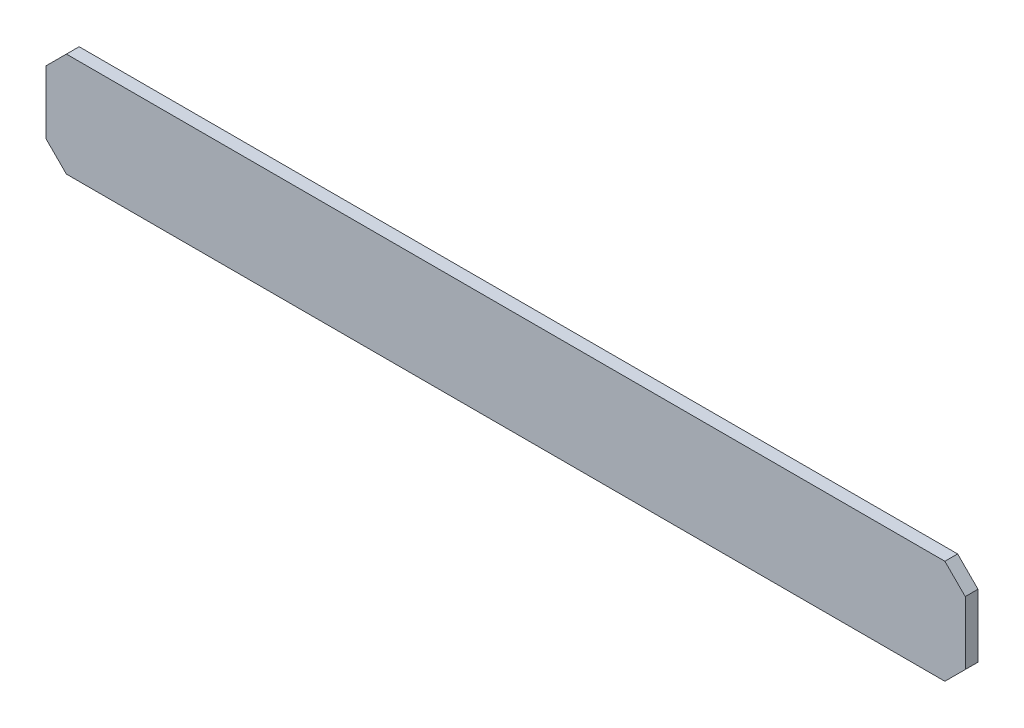
from build123d import *

# Parameters (mm, degrees)
SKETCH2_W           = 114.554000508
SKETCH2_H           = 12.954
BOSS_EXTRUDE1_DEPTH = 1.5875
CHAMFER1_SIZE       = 2.54


with BuildPart() as part:
    # Sketch2 → Boss-Extrude1 (new body)
    with BuildSketch(Plane.XY.offset(-4.7327)):
        with Locations((2.54e-07, -56.6198797)):
            Rectangle(SKETCH2_W, SKETCH2_H)
    extrude(amount=BOSS_EXTRUDE1_DEPTH)

    # Chamfer1
    chamfer1_edges = [part.edges().sort_by_distance(p)[0] for p in [
        (-57.277, -50.1428797, -3.93895),
        (57.277000508, -50.1428797, -3.93895),
        (57.277000508, -63.0968797, -3.93895),
        (-57.277, -63.0968797, -3.93895),
    ]]
    chamfer(chamfer1_edges, length=CHAMFER1_SIZE)


solid = part.part
